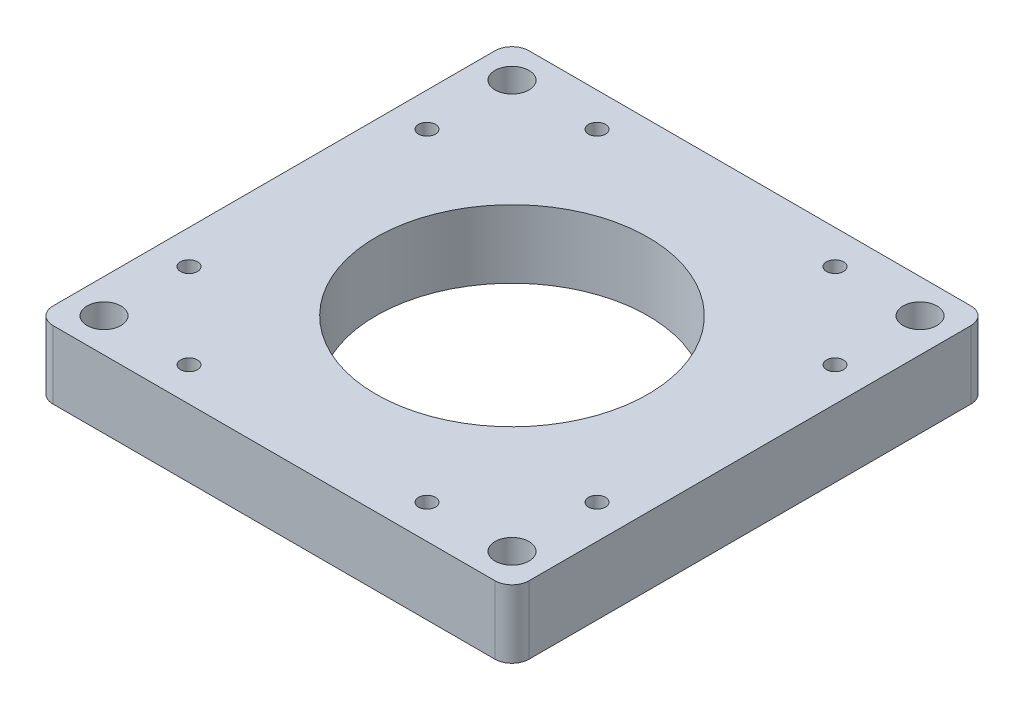
from build123d import *

# Parameters (mm, degrees)
SKETCH1_W           = 177.8
SKETCH1_H           = 177.8
SKETCH1_R           = 50.8
SKETCH1_R_2         = 3.175
SKETCH1_R_3         = 6.35
BOSS_EXTRUDE1_DEPTH = 25.4
FILLET1_R           = 6.35


with BuildPart() as part:
    # Sketch1 → Boss-Extrude1 (new body)
    with BuildSketch(Plane(origin=(0, 0, 0), x_dir=(1, 0, 0), z_dir=(0, 1, 0))):
        Rectangle(SKETCH1_W, SKETCH1_H)
        Circle(SKETCH1_R, mode=Mode.SUBTRACT)
        with Locations((44.45, 76.2)):
            Circle(SKETCH1_R_2, mode=Mode.SUBTRACT)
        with Locations((-44.45, 76.2)):
            Circle(SKETCH1_R_2, mode=Mode.SUBTRACT)
        with Locations((-76.2, 76.2)):
            Circle(SKETCH1_R_3, mode=Mode.SUBTRACT)
        with Locations((-76.2, -76.2)):
            Circle(SKETCH1_R_3, mode=Mode.SUBTRACT)
        with Locations((76.2, -76.2)):
            Circle(SKETCH1_R_3, mode=Mode.SUBTRACT)
        with Locations((76.2, 76.2)):
            Circle(SKETCH1_R_3, mode=Mode.SUBTRACT)
        with Locations((76.2, 44.45)):
            Circle(SKETCH1_R_2, mode=Mode.SUBTRACT)
        with Locations((76.2, -44.45)):
            Circle(SKETCH1_R_2, mode=Mode.SUBTRACT)
        with Locations((44.45, -76.2)):
            Circle(SKETCH1_R_2, mode=Mode.SUBTRACT)
        with Locations((-44.45, -76.2)):
            Circle(SKETCH1_R_2, mode=Mode.SUBTRACT)
        with Locations((-76.2, -44.45)):
            Circle(SKETCH1_R_2, mode=Mode.SUBTRACT)
        with Locations((-76.2, 44.45)):
            Circle(SKETCH1_R_2, mode=Mode.SUBTRACT)
    extrude(amount=BOSS_EXTRUDE1_DEPTH)

    # Fillet1
    fillet1_edges = [part.edges().sort_by_distance(p)[0] for p in [
        (-88.9, 12.7, -88.9),
        (88.9, 12.7, -88.9),
        (88.9, 12.7, 88.9),
        (-88.9, 12.7, 88.9),
    ]]
    fillet(fillet1_edges, radius=FILLET1_R)


solid = part.part
